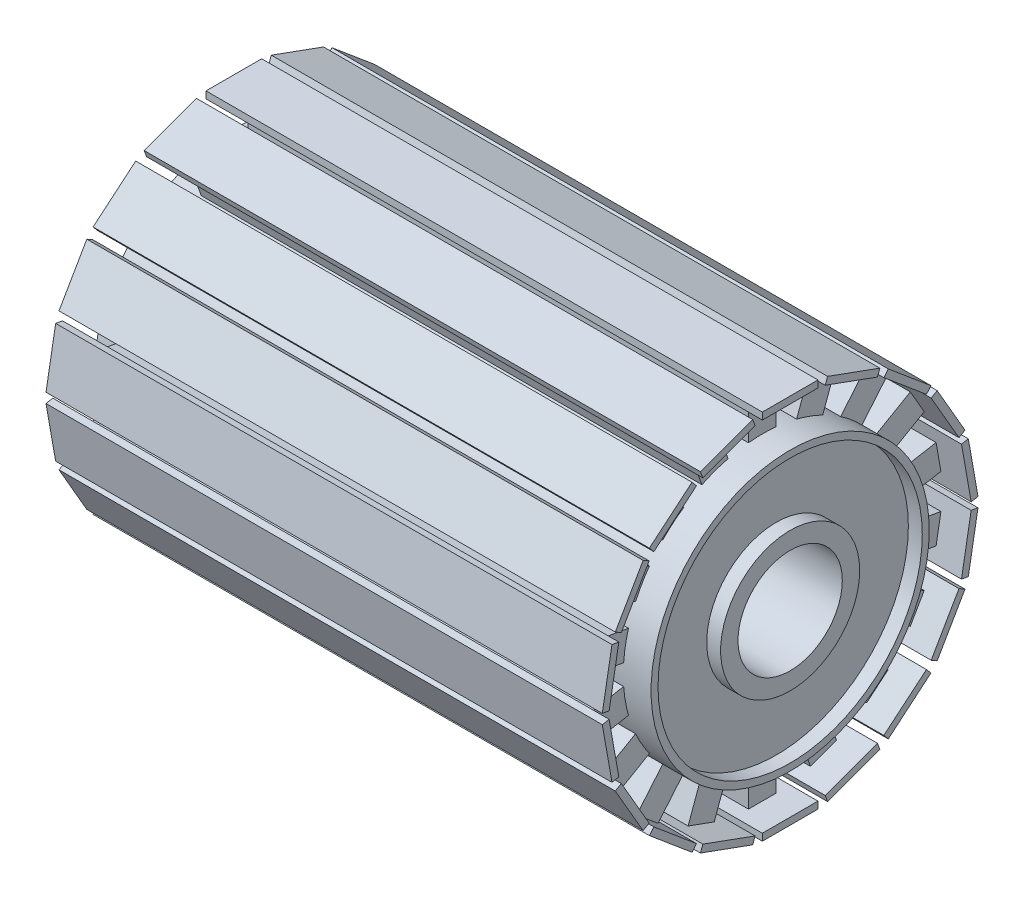
from build123d import *

# Parameters (mm, degrees)
SKETCH1_R               = 25.4
BOSS_EXTRUDE1_DEPTH     = 50.8
SKETCH2_R               = 24.13
SKETCH2_R_2             = 12.7
CUT_EXTRUDE1_DEPTH      = 2.54
SKETCH3_R               = 24.13
SKETCH3_R_2             = 12.7
CUT_EXTRUDE2_DEPTH      = 2.54
SKETCH4_W               = 5.08
SKETCH4_H               = 7.62
BOSS_EXTRUDE2_DEPTH     = 45.72
SKETCH5_W               = 101.6
SKETCH5_H               = 10.16
BOSS_EXTRUDE3_DEPTH     = 1.27
CIRPATTERN1_COUNT       = 18
SKETCH6_R               = 9.525
CUT_EXTRUDE3_DEPTH      = 1
CUT_EXTRUDE3_DEPTH_BACK = 102.6


with BuildPart() as part:
    # Sketch1 → Boss-Extrude1 (new body, symmetric)
    with BuildSketch(Plane(origin=(0, 0, 0), x_dir=(0, 0, -1), z_dir=(1, 0, 0))):
        Circle(SKETCH1_R)
    extrude(amount=BOSS_EXTRUDE1_DEPTH, both=True)

    # Sketch2 → Cut-Extrude1 (cut)
    with BuildSketch(Plane(origin=(50.8, 0, 0), x_dir=(0, 0, -1), z_dir=(1, 0, 0))):
        Circle(SKETCH2_R)
        Circle(SKETCH2_R_2, mode=Mode.SUBTRACT)
    extrude(amount=-CUT_EXTRUDE1_DEPTH, mode=Mode.SUBTRACT)

    # Sketch3 → Cut-Extrude2 (cut)
    with BuildSketch(Plane.ZY.offset(50.8)):
        Circle(SKETCH3_R)
        Circle(SKETCH3_R_2, mode=Mode.SUBTRACT)
    extrude(amount=-CUT_EXTRUDE2_DEPTH, mode=Mode.SUBTRACT)

    # Sketch4 → Boss-Extrude2 (add, symmetric)
    with BuildSketch(Plane(origin=(0, 0, 0), x_dir=(0, 0, -1), z_dir=(1, 0, 0))):
        with Locations((0, 28.861090904)):
            Rectangle(SKETCH4_W, SKETCH4_H)
    boss_extrude2 = extrude(amount=BOSS_EXTRUDE2_DEPTH, both=True)

    # Sketch5 → Boss-Extrude3 (add)
    with BuildSketch(Plane(origin=(0, 32.671090904, 0), x_dir=(1, 0, 0), z_dir=(0, 1, 0))):
        Rectangle(SKETCH5_W, SKETCH5_H)
    boss_extrude3 = extrude(amount=BOSS_EXTRUDE3_DEPTH)

    # CirPattern1: Boss-Extrude2, Boss-Extrude3 ×18 about axis
    cirpattern1_axis = Axis((0, 0, 0), (1, 0, 0))
    for i in range(1, CIRPATTERN1_COUNT):
        add(boss_extrude2.rotate(cirpattern1_axis, i * 360 / CIRPATTERN1_COUNT))
        add(boss_extrude3.rotate(cirpattern1_axis, i * 360 / CIRPATTERN1_COUNT))

    # Sketch6 → Cut-Extrude3 (cut, two sides)
    with BuildSketch(Plane(origin=(50.8, 0, 0), x_dir=(0, 0, -1), z_dir=(1, 0, 0))) as cut_extrude3_sk:
        Circle(SKETCH6_R)
    extrude(amount=CUT_EXTRUDE3_DEPTH, mode=Mode.SUBTRACT)
    extrude(cut_extrude3_sk.sketch, amount=-CUT_EXTRUDE3_DEPTH_BACK, mode=Mode.SUBTRACT)


solid = part.part
